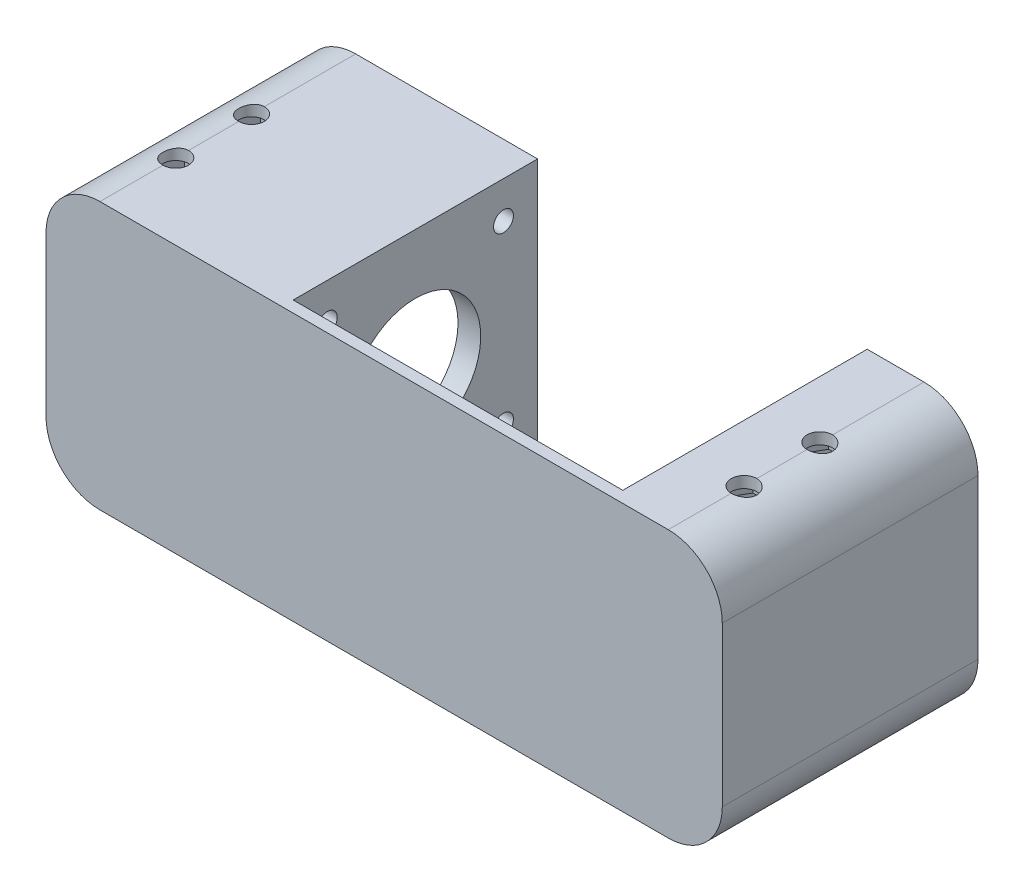
from build123d import *

# Parameters (mm, degrees)
BOSS_EXTRUDE1_DEPTH  = 43
SKETCH3_R            = 11.5
SKETCH3_R_2          = 1.75
CUT_EXTRUDE1_DEPTH   = 52
BOSS_EXTRUDE2_DEPTH  = 2
SKETCH5_R            = 2.25
CUT_EXTRUDE2_DEPTH   = 50
CUT_EXTRUDE3_DEPTH   = 2
MIRROR3_COPY_1_DEPTH = 2
SKETCH7_R            = 2.5
CUT_EXTRUDE4_DEPTH   = 19
CHAMFER1_SIZE        = 5


with BuildPart() as part:
    # Sketch2 → Boss-Extrude1 (new body)
    with BuildSketch(Plane.XY):
        with BuildLine():
            ThreePointArc((-59.5, 14), (-56.717514421, 20.717514421), (-50, 23.5))
            Line((-50, 23.5), (-18, 23.5))
            Line((-18, 23.5), (-18, -19.5))
            Line((-18, -19.5), (35, -19.5))
            Line((35, -19.5), (35, 23.5))
            Line((35, 23.5), (50, 23.5))
            ThreePointArc((50, 23.5), (56.717514421, 20.717514421), (59.5, 14))
            Line((59.5, 14), (59.5, -14))
            ThreePointArc((59.5, -14), (56.717514421, -20.717514421), (50, -23.5))
            Line((50, -23.5), (-50, -23.5))
            ThreePointArc((-50, -23.5), (-56.717514421, -20.717514421), (-59.5, -14))
            Line((-59.5, -14), (-59.5, 14))
        make_face()
        with BuildLine():
            ThreePointArc((50, -19.5), (53.889087297, -17.889087297), (55.5, -14))
            Line((55.5, -14), (55.5, 14))
            ThreePointArc((55.5, 14), (53.889087297, 17.889087297), (50, 19.5))
            Line((50, 19.5), (39, 19.5))
            Line((39, 19.5), (39, -19.5))
            Line((39, -19.5), (50, -19.5))
        make_face(mode=Mode.SUBTRACT)
        with BuildLine():
            Line((-55.5, -14), (-55.5, 14))
            ThreePointArc((-55.5, 14), (-53.889087297, 17.889087297), (-50, 19.5))
            Line((-50, 19.5), (-22, 19.5))
            Line((-22, 19.5), (-22, -19.5))
            Line((-22, -19.5), (-50, -19.5))
            ThreePointArc((-50, -19.5), (-53.889087297, -17.889087297), (-55.5, -14))
        make_face(mode=Mode.SUBTRACT)
    extrude(amount=BOSS_EXTRUDE1_DEPTH)

    # Sketch3 → Cut-Extrude1 (cut)
    with BuildSketch(Plane(origin=(-18, 0, 0), x_dir=(0, 0, -1), z_dir=(1, 0, 0))):
        with Locations((-21.5, 1.5)):
            Circle(SKETCH3_R)
        with Locations((-37, 17)):
            Circle(SKETCH3_R_2)
        with Locations((-37, -14)):
            Circle(SKETCH3_R_2)
        with Locations((-6, -14)):
            Circle(SKETCH3_R_2)
        with Locations((-6, 17)):
            Circle(SKETCH3_R_2)
    extrude(amount=-CUT_EXTRUDE1_DEPTH, mode=Mode.SUBTRACT)

    # Sketch4 → Boss-Extrude2 (add)
    with BuildSketch(Plane.XY.offset(43)):
        with BuildLine():
            Line((-18, 23.5), (35, 23.5))
            Line((35, 23.5), (50, 23.5))
            ThreePointArc((50, 23.5), (56.717514421, 20.717514421), (59.5, 14))
            Line((59.5, 14), (59.5, -14))
            ThreePointArc((59.5, -14), (56.717514421, -20.717514421), (50, -23.5))
            Line((50, -23.5), (-50, -23.5))
            ThreePointArc((-50, -23.5), (-56.717514421, -20.717514421), (-59.5, -14))
            Line((-59.5, -14), (-59.5, 14))
            ThreePointArc((-59.5, 14), (-56.717514421, 20.717514421), (-50, 23.5))
            Line((-50, 23.5), (-18, 23.5))
        make_face()
    extrude(amount=BOSS_EXTRUDE2_DEPTH)

    # Sketch5 → Cut-Extrude2 (cut)
    with BuildSketch(Plane(origin=(0, 23.5, 0), x_dir=(1, 0, 0), z_dir=(0, 1, 0))):
        with Locations((-50, -18.333333333)):
            Circle(SKETCH5_R)
        with Locations((-50, -31.666666667)):
            Circle(SKETCH5_R)
    cut_extrude2 = extrude(amount=-CUT_EXTRUDE2_DEPTH, mode=Mode.SUBTRACT)

    # Sketch6 → Cut-Extrude3 (cut, symmetric)
    with BuildSketch(Plane(origin=(0, -19.5, 0), x_dir=(1, 0, 0), z_dir=(0, 1, 0))):
        Polygon((-45.727608008, -18.333333333), (-47.863804004, -14.633333333), (-52.136195996, -14.633333333), (-54.272391992, -18.333333333), (-52.136195996, -22.033333333), (-47.863804004, -22.033333333), align=None)
        Polygon((-45.727608008, -31.666666667), (-47.863804004, -27.966666667), (-52.136195996, -27.966666667), (-54.272391992, -31.666666667), (-52.136195996, -35.366666667), (-47.863804004, -35.366666667), align=None)
    cut_extrude3 = extrude(amount=CUT_EXTRUDE3_DEPTH, both=True, mode=Mode.SUBTRACT)

    # Mirror1: Cut-Extrude2 across plane
    add(cut_extrude2.mirror(Plane(origin=(0, 0, 0), x_dir=(0, 0, 1), z_dir=(1, 0, 0))), mode=Mode.SUBTRACT)

    # Mirror2: Cut-Extrude3 across plane
    add(cut_extrude3.mirror(Plane.ZX), mode=Mode.SUBTRACT)

    # Mirror3: Cut-Extrude3 across plane
    add(cut_extrude3.mirror(Plane(origin=(0, 0, 0), x_dir=(0, 0, 1), z_dir=(1, 0, 0))), mode=Mode.SUBTRACT)

    # Mirror3 copy 1 sketch → Mirror3 copy 1 (cut, symmetric)
    with BuildSketch(Plane(origin=(0, 19.5, 0), x_dir=(-1, 0, 0), z_dir=(0, -1, 0))):
        Polygon((-45.727608008, -18.333333333), (-47.863804004, -14.633333333), (-52.136195996, -14.633333333), (-54.272391992, -18.333333333), (-52.136195996, -22.033333333), (-47.863804004, -22.033333333), align=None)
        Polygon((-45.727608008, -31.666666667), (-47.863804004, -27.966666667), (-52.136195996, -27.966666667), (-54.272391992, -31.666666667), (-52.136195996, -35.366666667), (-47.863804004, -35.366666667), align=None)
    extrude(amount=MIRROR3_COPY_1_DEPTH, both=True, mode=Mode.SUBTRACT)

    # Sketch7 → Cut-Extrude4 (cut)
    with BuildSketch(Plane.ZY.offset(59.5)):
        with Locations((6, 17)):
            Circle(SKETCH7_R)
        with Locations((37, 17)):
            Circle(SKETCH7_R)
        with Locations((37, -14)):
            Circle(SKETCH7_R)
        with Locations((6, -14)):
            Circle(SKETCH7_R)
    extrude(amount=-CUT_EXTRUDE4_DEPTH, mode=Mode.SUBTRACT)

    # Chamfer1
    chamfer1_edges = [part.edges().sort_by_distance(p)[0] for p in [
        (35, -19.5, 21.5),
        (35, 23.5, 21.5),
        (39, 19.5, 21.5),
        (39, -19.5, 21.5),
    ]]
    chamfer(chamfer1_edges, length=CHAMFER1_SIZE)


solid = part.part
